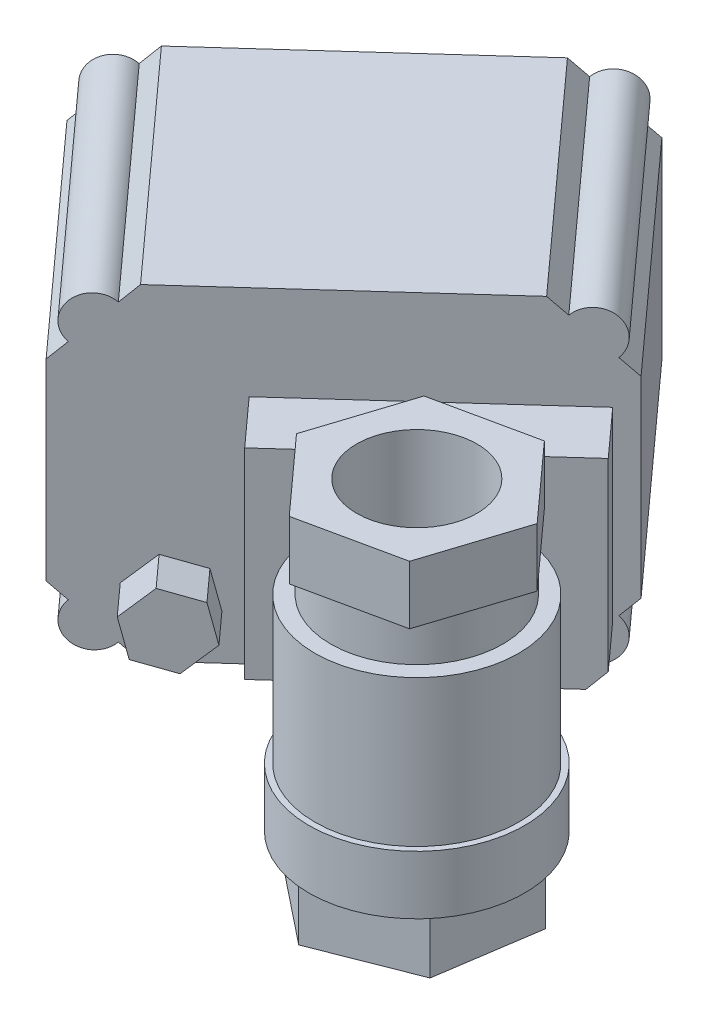
from build123d import *

# Parameters (mm, degrees)
BOSS_EXTRUDE1_DEPTH  = 8.636
SKETCH2_R            = 16.383
BOSS_EXTRUDE2_DEPTH  = 8.89
SKETCH5_R            = 15.494
BOSS_EXTRUDE3_DEPTH  = 22.225
SKETCH6_R            = 13.081
BOSS_EXTRUDE4_DEPTH  = 6.35
BOSS_EXTRUDE5_DEPTH  = 8.89
SKETCH19_R           = 8.509
BOSS_EXTRUDE9_DEPTH  = 20.574
SKETCH26_R           = 9.144
CUT_EXTRUDE1_DEPTH   = 55.991
SKETCH28_W           = 39.116
SKETCH28_H           = 30.48
BOSS_EXTRUDE11_DEPTH = 9.525
SKETCH29_W           = 64.008
SKETCH29_H           = 49.53
BOSS_EXTRUDE12_DEPTH = 44.45
BOSS_EXTRUDE13_DEPTH = 6.35
CUT_EXTRUDE2_REACH   = 99.689
BOSS_EXTRUDE14_DEPTH = 44.45


with BuildPart() as part:
    # Sketch1 → Boss-Extrude1 (new body)
    with BuildSketch(Plane(origin=(0, 0, 0), x_dir=(1, 0, 0), z_dir=(0, 1, 0))):
        Polygon((3.618323339, -5.199254385), (5.90723301, 10.02760322), (-6.13515766, 19.623285945), (-20.466458001, 13.992111064), (-22.755367672, -1.234746541), (-10.712977002, -10.830429265), align=None)
    extrude(amount=BOSS_EXTRUDE1_DEPTH)

    # Sketch2 → Boss-Extrude2 (add)
    with BuildSketch(Plane(origin=(0, 8.636, 0), x_dir=(1, 0, 0), z_dir=(0, 1, 0))):
        with Locations((-8.116287221, 4.517363885)):
            Circle(SKETCH2_R)
    extrude(amount=BOSS_EXTRUDE2_DEPTH)

    # Sketch5 → Boss-Extrude3 (add)
    with BuildSketch(Plane(origin=(0, 17.526, 0), x_dir=(1, 0, 0), z_dir=(0, 1, 0))):
        with Locations((-8.116287221, 4.517363885)):
            Circle(SKETCH5_R)
    extrude(amount=BOSS_EXTRUDE3_DEPTH)

    # Sketch6 → Boss-Extrude4 (add)
    with BuildSketch(Plane(origin=(0, 39.751, 0), x_dir=(1, 0, 0), z_dir=(0, 1, 0))):
        with Locations((-8.116287221, 4.517363885)):
            Circle(SKETCH6_R)
    extrude(amount=BOSS_EXTRUDE4_DEPTH)

    # Sketch8 → Boss-Extrude5 (add)
    with BuildSketch(Plane(origin=(0, 46.101, 0), x_dir=(1, 0, 0), z_dir=(0, 1, 0))):
        Polygon((-18.441823617, 15.940130543), (-23.171461527, 1.286570387), (-12.845925131, -10.136196271), (2.209249175, -6.905402773), (6.938887085, 7.748157383), (-3.386649312, 19.170924041), align=None)
    extrude(amount=BOSS_EXTRUDE5_DEPTH)

    # Sketch19 → Boss-Extrude9 (add)
    with BuildSketch(Plane(origin=(-5.896918877, 0, -6.523547615), x_dir=(-0.741837728, 0, 0.67057944), z_dir=(-0.67057944, 0, -0.741837728))):
        with Locations((2.991716732, 28.575)):
            Circle(SKETCH19_R)
    extrude(amount=BOSS_EXTRUDE9_DEPTH)

    # Sketch26 → Cut-Extrude1 (cut, through all)
    with BuildSketch(Plane(origin=(0, 54.991, 0), x_dir=(1, 0, 0), z_dir=(0, 1, 0))):
        with Locations((-8.116287221, 4.517363885)):
            Circle(SKETCH26_R)
    extrude(amount=-CUT_EXTRUDE1_DEPTH, mode=Mode.SUBTRACT)

    # Sketch28 → Boss-Extrude11 (add)
    with BuildSketch(Plane(origin=(-19.693420267, 0, -21.786117038), x_dir=(-0.741837728, 0, 0.67057944), z_dir=(-0.67057944, 0, -0.741837728))):
        with Locations((2.991716732, 28.575)):
            Rectangle(SKETCH28_W, SKETCH28_H)
    extrude(amount=BOSS_EXTRUDE11_DEPTH)

    # Sketch29 → Boss-Extrude12 (add)
    with BuildSketch(Plane(origin=(-26.080689429, 0, -28.852121401), x_dir=(-0.741837728, 0, 0.67057944), z_dir=(-0.67057944, 0, -0.741837728))):
        with Locations((12.389716732, 33.401)):
            Rectangle(SKETCH29_W, SKETCH29_H)
    extrude(amount=BOSS_EXTRUDE12_DEPTH)

    # Sketch31 → Boss-Extrude13 (add)
    with BuildSketch(Plane(origin=(-26.080689429, 0, -28.852121401), x_dir=(0.741837728, 0, -0.67057944), z_dir=(0.67057944, 0, 0.741837728))):
        Polygon((-29.660890196, 11.58925085), (-25.479774792, 15.49154325), (-26.768701441, 21.063641607), (-32.238743495, 22.733447563), (-36.419858899, 18.831155162), (-35.130932249, 13.259056806), align=None)
    extrude(amount=BOSS_EXTRUDE13_DEPTH)

    # Sketch36 → Cut-Extrude2 (cut, up to next)
    with BuildSketch(Plane(origin=(-55.887945518, 0, -61.826808426), x_dir=(-0.741837728, 0, 0.67057944), z_dir=(-0.67057944, 0, -0.741837728)), mode=Mode.PRIVATE) as cut_extrude2_sk1:
        Polygon((34.233716732, 8.636), (44.393716732, 18.796), (44.393716732, 8.636), align=None)
    cut_extrude2_tool1 = extrude(cut_extrude2_sk1.sketch, amount=-CUT_EXTRUDE2_REACH, mode=Mode.PRIVATE) & part.part
    add(cut_extrude2_tool1.solids().sort_by_distance((-86.308522, 12.022667, -34.328324))[0], mode=Mode.SUBTRACT)
    # Sketch36 → Cut-Extrude2 (cut, up to next)
    with BuildSketch(Plane(origin=(-55.887945518, 0, -61.826808426), x_dir=(-0.741837728, 0, 0.67057944), z_dir=(-0.67057944, 0, -0.741837728)), mode=Mode.PRIVATE) as cut_extrude2_sk2:
        Polygon((-9.454283268, 8.636), (-19.614283268, 18.796), (-19.614283268, 8.636), align=None)
    cut_extrude2_tool2 = extrude(cut_extrude2_sk2.sketch, amount=-CUT_EXTRUDE2_REACH, mode=Mode.PRIVATE) & part.part
    add(cut_extrude2_tool2.solids().sort_by_distance((-43.849687, 12.022667, -72.708714))[0], mode=Mode.SUBTRACT)
    # Sketch36 → Cut-Extrude2 (cut, up to next)
    with BuildSketch(Plane(origin=(-55.887945518, 0, -61.826808426), x_dir=(-0.741837728, 0, 0.67057944), z_dir=(-0.67057944, 0, -0.741837728)), mode=Mode.PRIVATE) as cut_extrude2_sk3:
        Polygon((-19.614283268, 48.006), (-9.454283268, 58.166), (-19.614283268, 58.166), align=None)
    cut_extrude2_tool3 = extrude(cut_extrude2_sk3.sketch, amount=-CUT_EXTRUDE2_REACH, mode=Mode.PRIVATE) & part.part
    add(cut_extrude2_tool3.solids().sort_by_distance((-43.849687, 54.779333, -72.708714))[0], mode=Mode.SUBTRACT)
    # Sketch36 → Cut-Extrude2 (cut, up to next)
    with BuildSketch(Plane(origin=(-55.887945518, 0, -61.826808426), x_dir=(-0.741837728, 0, 0.67057944), z_dir=(-0.67057944, 0, -0.741837728)), mode=Mode.PRIVATE) as cut_extrude2_sk4:
        Polygon((44.393716732, 48.006), (34.233716732, 58.166), (44.393716732, 58.166), align=None)
    cut_extrude2_tool4 = extrude(cut_extrude2_sk4.sketch, amount=-CUT_EXTRUDE2_REACH, mode=Mode.PRIVATE) & part.part
    add(cut_extrude2_tool4.solids().sort_by_distance((-86.308522, 54.779333, -34.328324))[0], mode=Mode.SUBTRACT)

    # Sketch37 → Boss-Extrude14 (add)
    with BuildSketch(Plane(origin=(-55.887945518, 0, -61.826808426), x_dir=(-0.741837728, 0, 0.67057944), z_dir=(-0.67057944, 0, -0.741837728))):
        with BuildLine():
            Line((42.007793569, 16.410076836), (36.619639896, 11.021923164))
            ThreePointArc((36.619639896, 11.021923164), (42.007793569, 11.021923164), (42.007793569, 16.410076836))
        make_face()
        with BuildLine():
            Line((-11.840206431, 11.021923164), (-17.228360104, 16.410076836))
            ThreePointArc((-17.228360104, 16.410076836), (-17.228360104, 11.021923164), (-11.840206431, 11.021923164))
        make_face()
        with BuildLine():
            Line((-17.228360104, 50.391923164), (-11.840206431, 55.780076836))
            ThreePointArc((-11.840206431, 55.780076836), (-17.228360104, 55.780076836), (-17.228360104, 50.391923164))
        make_face()
        with BuildLine():
            Line((36.619639896, 55.780076836), (42.007793569, 50.391923164))
            ThreePointArc((42.007793569, 50.391923164), (42.007793569, 55.780076836), (36.619639896, 55.780076836))
        make_face()
    extrude(amount=-BOSS_EXTRUDE14_DEPTH)


solid = part.part
